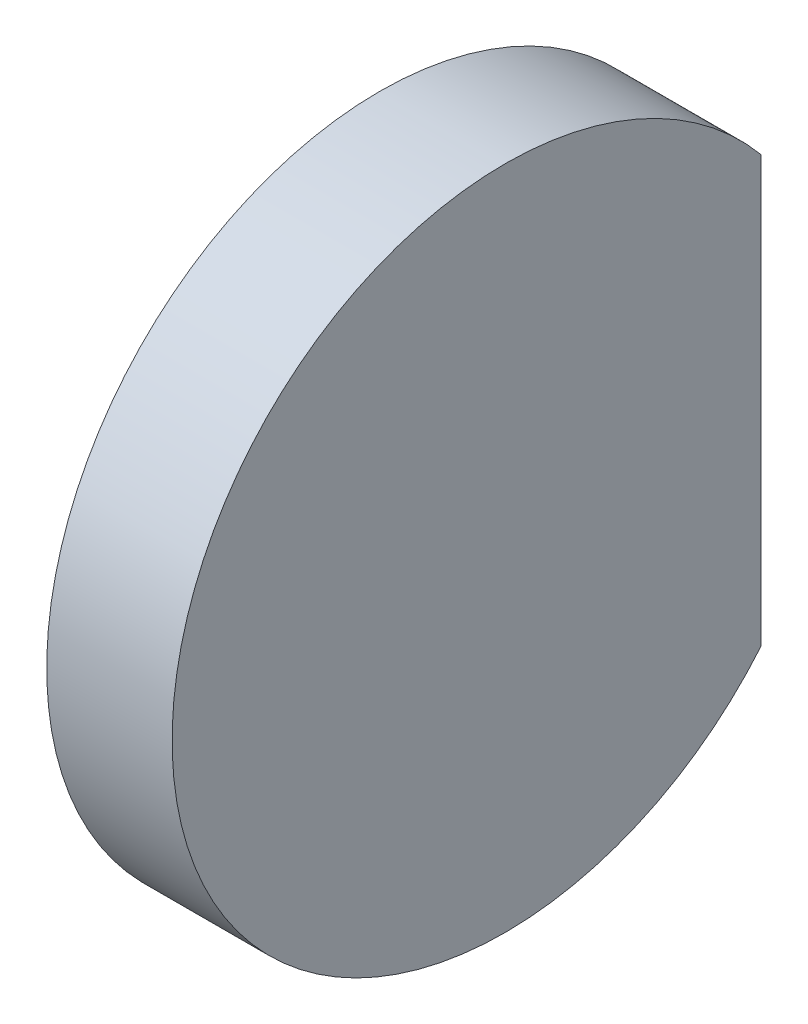
from build123d import *

# Parameters (mm, degrees)
CUT_EXTRUDE_1_DEPTH = 4


with BuildPart() as part:
    # Эскиз1 → Повернуть1 (revolve)
    with BuildSketch(Plane.XY):
        with BuildLine():
            Line((0.551940839, 6.5), (3, 6.5))
            Line((3, 6.5), (3, 0))
            Line((3, 0), (0, 0))
            ThreePointArc((0, 0), (0.138233049, 3.261695828), (0.551940839, 6.5))
        make_face()
    revolve(axis=Axis((0, 0, 0), (1, 0, 0)))

    # Эскиз2 → Вырез-Вытянуть1 (cut, through all)
    with BuildSketch(Plane(origin=(3, 0, 0), x_dir=(0, 0, -1), z_dir=(1, 0, 0))):
        Polygon((5, 45.505699726), (5, 4.153311931), (5, -4.153311931), (5, -45.505699726), (87.70477559, -45.505699726), (87.70477559, 45.505699726), align=None)
    extrude(amount=-CUT_EXTRUDE_1_DEPTH, mode=Mode.SUBTRACT)


solid = part.part
